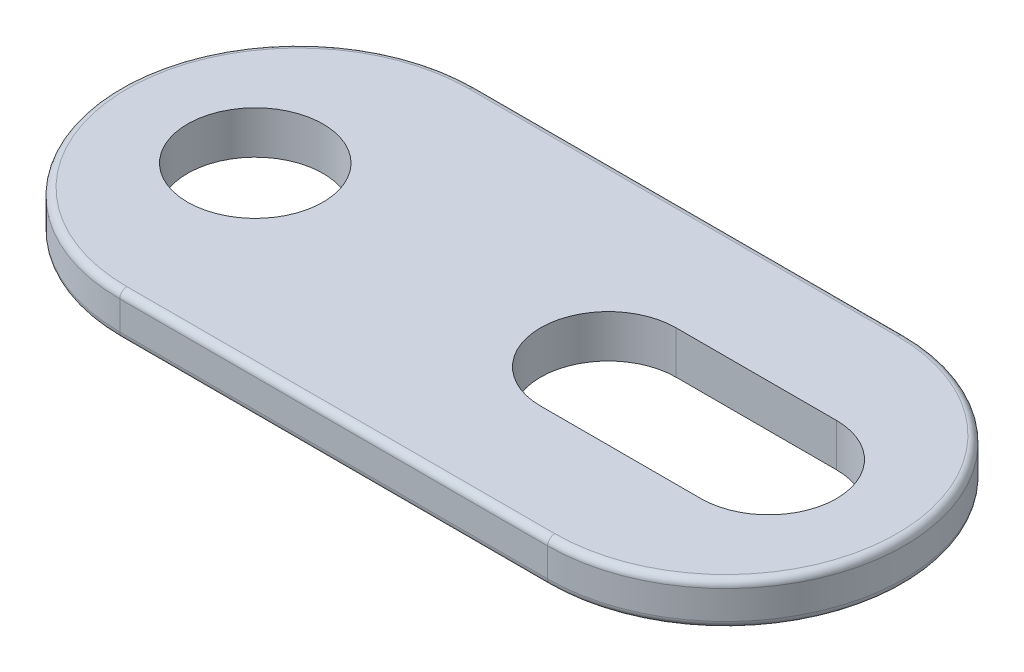
from build123d import *

# Parameters (mm, degrees)
SKETCH1_R      = 2.413
EXTRUDE1_DEPTH = 0.762
FILLET1_R      = 0.254


with BuildPart() as part:
    # Sketch1 → Extrude1 (new body, symmetric)
    with BuildSketch(Plane(origin=(0, 0, 0), x_dir=(1, 0, 0), z_dir=(0, 1, 0))):
        with BuildLine():
            Line((1.524, -6.35), (16.764, -6.35))
            ThreePointArc((16.764, -6.35), (23.114, 0), (16.764, 6.35))
            Line((16.764, 6.35), (1.524, 6.35))
            ThreePointArc((1.524, 6.35), (-4.826, 0), (1.524, -6.35))
        make_face()
        Circle(SKETCH1_R, mode=Mode.SUBTRACT)
        with BuildLine():
            Line((12.573, 2.413), (18.288, 2.413))
            ThreePointArc((18.288, 2.413), (20.701, 0), (18.288, -2.413))
            Line((18.288, -2.413), (12.573, -2.413))
            ThreePointArc((12.573, -2.413), (10.16, 0), (12.573, 2.413))
        make_face(mode=Mode.SUBTRACT)
    extrude(amount=EXTRUDE1_DEPTH, both=True)

    # Fillet1
    fillet1_edges = [part.edges().sort_by_distance(p)[0] for p in [
        (23.114, 0.762, 0),
        (9.144, 0.762, -6.35),
        (-4.826, 0.762, 0),
        (9.144, -0.762, -6.35),
        (23.114, -0.762, 0),
        (9.144, -0.762, 6.35),
        (-4.826, -0.762, 0),
        (9.144, 0.762, 6.35),
    ]]
    fillet(fillet1_edges, radius=FILLET1_R)


solid = part.part
